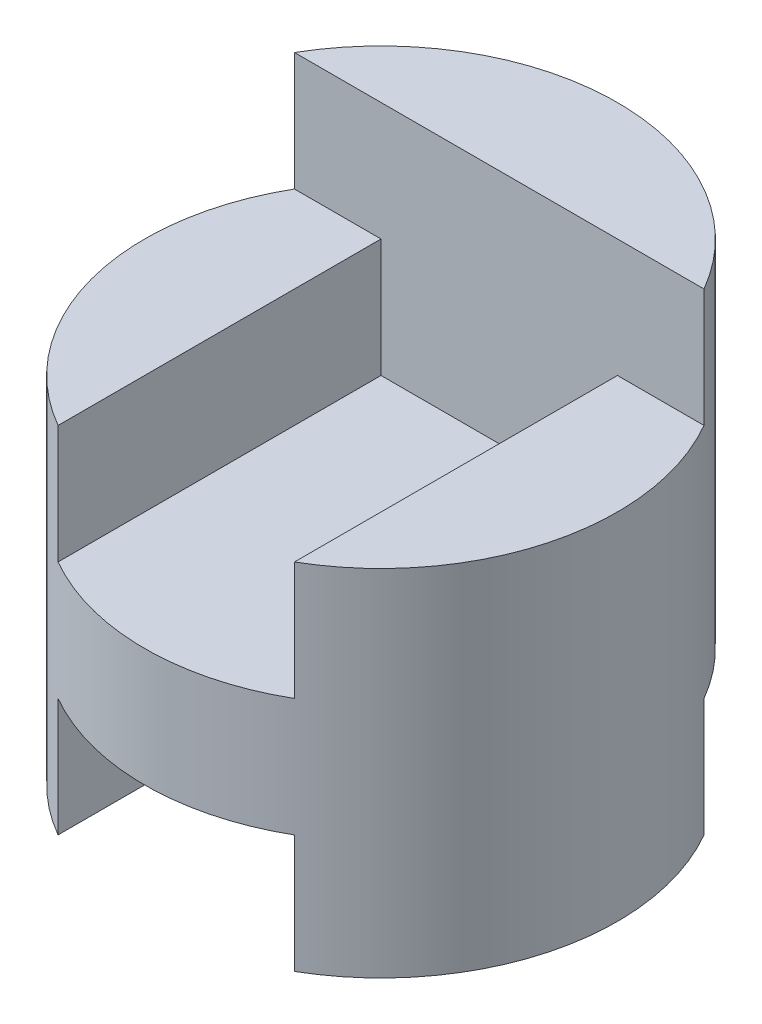
from build123d import *

# Parameters (mm, degrees)
SKETCH1_R               = 2
BOSS_EXTRUDE1_DEPTH     = 4
SKETCH2_W               = 2
SKETCH2_H               = 1
CUT_EXTRUDE1_DEPTH      = 2
CUT_EXTRUDE2_DEPTH      = 4
CUT_EXTRUDE2_DEPTH_BACK = 1
SKETCH4_W               = 0.732050808
SKETCH4_H               = 1
CUT_EXTRUDE3_DEPTH      = 5


with BuildPart() as part:
    # Sketch1 → Boss-Extrude1 (new body)
    with BuildSketch(Plane(origin=(0, 0, 0), x_dir=(1, 0, 0), z_dir=(0, 1, 0))):
        Circle(SKETCH1_R)
    extrude(amount=BOSS_EXTRUDE1_DEPTH)

    # Sketch2 → Cut-Extrude1 (cut, symmetric)
    with BuildSketch(Plane.XY):
        with Locations((0, 0.5)):
            Rectangle(SKETCH2_W, SKETCH2_H)
    extrude(amount=CUT_EXTRUDE1_DEPTH, both=True, mode=Mode.SUBTRACT)

    # Sketch3 → Cut-Extrude2 (cut, two sides)
    with BuildSketch(Plane.XY) as cut_extrude2_sk:
        Polygon((-2, 4), (2, 4), (2, 3), (1, 3), (1, 2), (-1, 2), (-1, 3), (-2, 3), align=None)
    extrude(amount=CUT_EXTRUDE2_DEPTH, mode=Mode.SUBTRACT)
    extrude(cut_extrude2_sk.sketch, amount=-CUT_EXTRUDE2_DEPTH_BACK, mode=Mode.SUBTRACT)

    # Sketch4 → Cut-Extrude3 (cut, symmetric)
    with BuildSketch(Plane(origin=(0, 0, 0), x_dir=(0, 0, -1), z_dir=(1, 0, 0))):
        with Locations((1.366025404, 0.5)):
            Rectangle(SKETCH4_W, SKETCH4_H)
    extrude(amount=CUT_EXTRUDE3_DEPTH, both=True, mode=Mode.SUBTRACT)


solid = part.part
